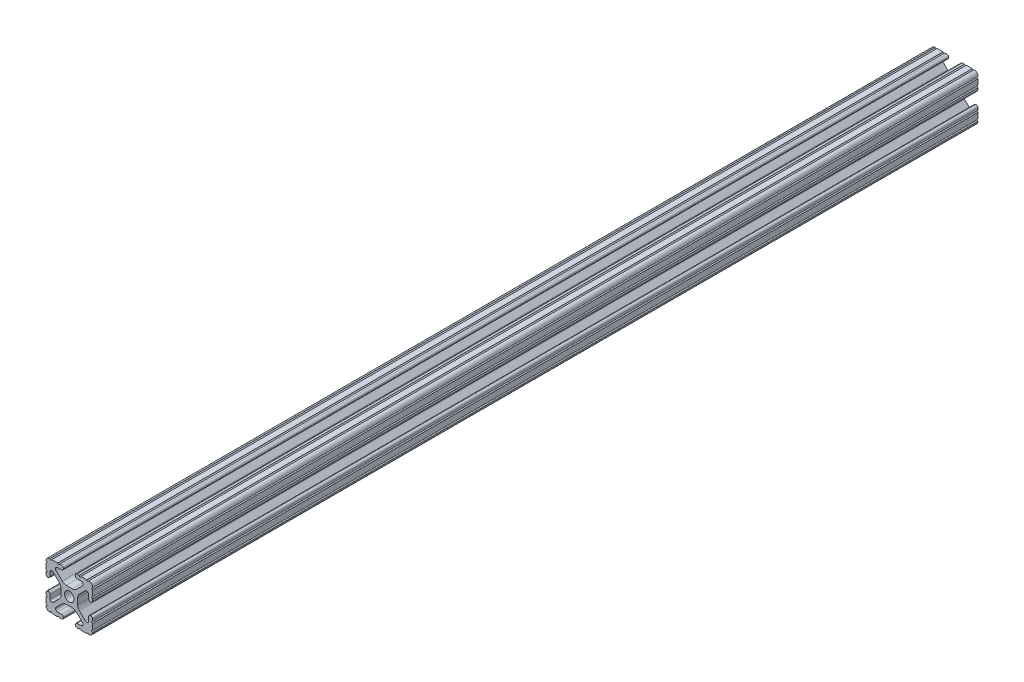
from build123d import *

# Parameters (mm, degrees)
SKETCH1_R           = 2.6035
BOSS_EXTRUDE1_DEPTH = 241.3


with BuildPart() as part:
    # Sketch1 → Boss-Extrude1 (new body, symmetric)
    with BuildSketch(Plane.XY):
        with BuildLine():
            Line((-7.179650497, -8.645192506), (-3.952270251, -5.423690499))
            ThreePointArc((-3.952270251, -5.423690499), (-2.922936451, -4.736929036), (-1.709253557, -4.4958))
            Line((-1.709253557, -4.4958), (1.709253557, -4.4958))
            ThreePointArc((1.709253557, -4.4958), (2.922936451, -4.736929036), (3.952270251, -5.423690499))
            Line((3.952270251, -5.423690499), (7.179650497, -8.645192506))
            ThreePointArc((7.179650497, -8.645192506), (7.41473083, -9.822813117), (6.416408329, -10.4902))
            Line((6.416408329, -10.4902), (4.287512407, -10.4902))
            ThreePointArc((4.287512407, -10.4902), (3.54574862, -10.79744862), (3.2385, -11.539212407))
            Line((3.2385, -11.539212407), (3.2385, -11.650987593))
            ThreePointArc((3.2385, -11.650987593), (3.54574862, -12.39275138), (4.287512407, -12.7))
            Line((4.287512407, -12.7), (5.317126718, -12.7))
            ThreePointArc((5.317126718, -12.7), (5.825126718, -12.192), (6.333126718, -12.7))
            Line((6.333126718, -12.7), (9.550443118, -12.7))
            ThreePointArc((9.550443118, -12.7), (10.058366869, -12.192000006), (10.566443095, -12.699847501))
            ThreePointArc((10.566443095, -12.699847501), (12.082537762, -12.08250727), (12.699846982, -10.566399977))
            ThreePointArc((12.699846982, -10.566399977), (12.192000006, -10.058323491), (12.7, -9.5504))
            Line((12.7, -9.5504), (12.7, -6.3330836))
            ThreePointArc((12.7, -6.3330836), (12.192, -5.8250836), (12.7, -5.3170836))
            Line((12.7, -5.3170836), (12.7, -4.287469289))
            ThreePointArc((12.7, -4.287469289), (12.39275138, -3.545705502), (11.650987593, -3.238456882))
            Line((11.650987593, -3.238456882), (11.539212407, -3.238456882))
            ThreePointArc((11.539212407, -3.238456882), (10.79744862, -3.545705502), (10.4902, -4.287469289))
            Line((10.4902, -4.287469289), (10.4902, -6.402089023))
            ThreePointArc((10.4902, -6.402089023), (9.856505071, -7.351067942), (8.737131347, -7.129408934))
            Line((8.737131347, -7.129408934), (5.441005833, -3.840816462))
            ThreePointArc((5.441005833, -3.840816462), (4.750877967, -2.809883091), (4.5085, -1.593185507))
            Line((4.5085, -1.593185507), (4.5085, 1.593185507))
            ThreePointArc((4.5085, 1.593185507), (4.750877967, 2.809883091), (5.441005833, 3.840816462))
            Line((5.441005833, 3.840816462), (8.737131347, 7.129408934))
            ThreePointArc((8.737131347, 7.129408934), (9.856505071, 7.351067942), (10.4902, 6.402089023))
            Line((10.4902, 6.402089023), (10.4902, 4.287469289))
            ThreePointArc((10.4902, 4.287469289), (10.79744862, 3.545705502), (11.539212407, 3.238456882))
            Line((11.539212407, 3.238456882), (11.650987593, 3.238456882))
            ThreePointArc((11.650987593, 3.238456882), (12.39275138, 3.545705502), (12.7, 4.287469289))
            Line((12.7, 4.287469289), (12.7, 5.3170836))
            ThreePointArc((12.7, 5.3170836), (12.192, 5.8250836), (12.7, 6.3330836))
            Line((12.7, 6.3330836), (12.7, 9.5504))
            ThreePointArc((12.7, 9.5504), (12.192000006, 10.058323491), (12.699846982, 10.566399977))
            ThreePointArc((12.699846982, 10.566399977), (12.082537762, 12.08250727), (10.566443095, 12.699847501))
            ThreePointArc((10.566443095, 12.699847501), (10.058366869, 12.192000006), (9.550443118, 12.7))
            Line((9.550443118, 12.7), (6.333126718, 12.7))
            ThreePointArc((6.333126718, 12.7), (5.825126718, 12.192), (5.317126718, 12.7))
            Line((5.317126718, 12.7), (4.287512407, 12.7))
            ThreePointArc((4.287512407, 12.7), (3.54574862, 12.39275138), (3.2385, 11.650987593))
            Line((3.2385, 11.650987593), (3.2385, 11.539212407))
            ThreePointArc((3.2385, 11.539212407), (3.54574862, 10.79744862), (4.287512407, 10.4902))
            Line((4.287512407, 10.4902), (6.476788598, 10.4902))
            ThreePointArc((6.476788598, 10.4902), (7.432222385, 9.85140422), (7.207036008, 8.724370562))
            Line((7.207036008, 8.724370562), (3.898272566, 5.423169045))
            ThreePointArc((3.898272566, 5.423169045), (2.869120213, 4.736787962), (1.655778399, 4.4958))
            Line((1.655778399, 4.4958), (-1.655778399, 4.4958))
            ThreePointArc((-1.655778399, 4.4958), (-2.869120213, 4.736787962), (-3.898272566, 5.423169045))
            Line((-3.898272566, 5.423169045), (-7.207036008, 8.724370562))
            ThreePointArc((-7.207036008, 8.724370562), (-7.432222385, 9.85140422), (-6.476788598, 10.4902))
            Line((-6.476788598, 10.4902), (-4.287512407, 10.4902))
            ThreePointArc((-4.287512407, 10.4902), (-3.54574862, 10.79744862), (-3.2385, 11.539212407))
            Line((-3.2385, 11.539212407), (-3.2385, 11.650987593))
            ThreePointArc((-3.2385, 11.650987593), (-3.54574862, 12.39275138), (-4.287512407, 12.7))
            Line((-4.287512407, 12.7), (-5.317126718, 12.7))
            ThreePointArc((-5.317126718, 12.7), (-5.825126718, 12.192), (-6.333126718, 12.7))
            Line((-6.333126718, 12.7), (-9.550443118, 12.7))
            ThreePointArc((-9.550443118, 12.7), (-10.058366869, 12.192000006), (-10.566443095, 12.699847501))
            ThreePointArc((-10.566443095, 12.699847501), (-12.082537762, 12.08250727), (-12.699846982, 10.566399977))
            ThreePointArc((-12.699846982, 10.566399977), (-12.192000006, 10.058323491), (-12.7, 9.5504))
            Line((-12.7, 9.5504), (-12.7, 6.3330836))
            ThreePointArc((-12.7, 6.3330836), (-12.192, 5.8250836), (-12.7, 5.3170836))
            Line((-12.7, 5.3170836), (-12.7, 4.287469289))
            ThreePointArc((-12.7, 4.287469289), (-12.39275138, 3.545705502), (-11.650987593, 3.238456882))
            Line((-11.650987593, 3.238456882), (-11.539212407, 3.238456882))
            ThreePointArc((-11.539212407, 3.238456882), (-10.79744862, 3.545705502), (-10.4902, 4.287469289))
            Line((-10.4902, 4.287469289), (-10.4902, 6.402089023))
            ThreePointArc((-10.4902, 6.402089023), (-9.856505071, 7.351067942), (-8.737131347, 7.129408934))
            Line((-8.737131347, 7.129408934), (-5.441005833, 3.840816462))
            ThreePointArc((-5.441005833, 3.840816462), (-4.750877967, 2.809883091), (-4.5085, 1.593185507))
            Line((-4.5085, 1.593185507), (-4.5085, -1.593185507))
            ThreePointArc((-4.5085, -1.593185507), (-4.750877967, -2.809883091), (-5.441005833, -3.840816462))
            Line((-5.441005833, -3.840816462), (-8.737131347, -7.129408934))
            ThreePointArc((-8.737131347, -7.129408934), (-9.856505071, -7.351067942), (-10.4902, -6.402089023))
            Line((-10.4902, -6.402089023), (-10.4902, -4.287469289))
            ThreePointArc((-10.4902, -4.287469289), (-10.79744862, -3.545705502), (-11.539212407, -3.238456882))
            Line((-11.539212407, -3.238456882), (-11.650987593, -3.238456882))
            ThreePointArc((-11.650987593, -3.238456882), (-12.39275138, -3.545705502), (-12.7, -4.287469289))
            Line((-12.7, -4.287469289), (-12.7, -5.3170836))
            ThreePointArc((-12.7, -5.3170836), (-12.192, -5.8250836), (-12.7, -6.3330836))
            Line((-12.7, -6.3330836), (-12.7, -9.5504))
            ThreePointArc((-12.7, -9.5504), (-12.192000006, -10.058323491), (-12.699846982, -10.566399977))
            ThreePointArc((-12.699846982, -10.566399977), (-12.082537762, -12.08250727), (-10.566443095, -12.699847501))
            ThreePointArc((-10.566443095, -12.699847501), (-10.058366869, -12.192000006), (-9.550443118, -12.7))
            Line((-9.550443118, -12.7), (-6.333126718, -12.7))
            ThreePointArc((-6.333126718, -12.7), (-5.825126718, -12.192), (-5.317126718, -12.7))
            Line((-5.317126718, -12.7), (-4.287512407, -12.7))
            ThreePointArc((-4.287512407, -12.7), (-3.54574862, -12.39275138), (-3.2385, -11.650987593))
            Line((-3.2385, -11.650987593), (-3.2385, -11.539212407))
            ThreePointArc((-3.2385, -11.539212407), (-3.54574862, -10.79744862), (-4.287512407, -10.4902))
            Line((-4.287512407, -10.4902), (-6.416408329, -10.4902))
            ThreePointArc((-6.416408329, -10.4902), (-7.41473083, -9.822813117), (-7.179650497, -8.645192506))
        make_face()
        Circle(SKETCH1_R, mode=Mode.SUBTRACT)
    extrude(amount=BOSS_EXTRUDE1_DEPTH, both=True)


solid = part.part
